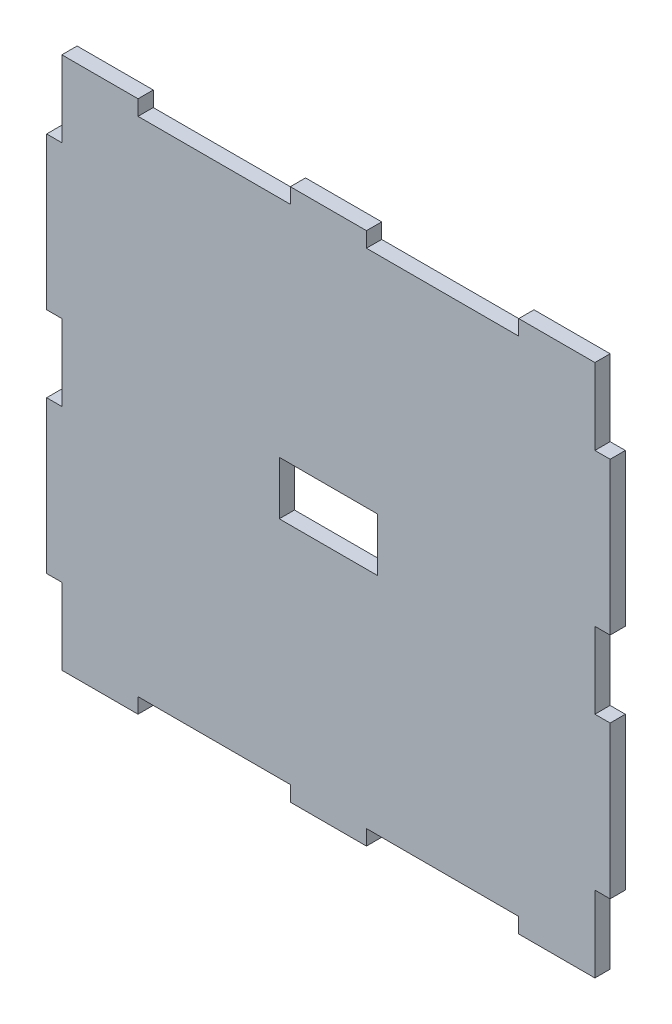
from build123d import *

# Parameters (mm, degrees)
SKETCH1_W           = 70
SKETCH1_H           = 70
BOSS_EXTRUDE1_DEPTH = 2
SKETCH2_W           = 2
SKETCH2_H           = 20
BOSS_EXTRUDE2_DEPTH = 2
SKETCH3_W           = 20
SKETCH3_H           = 2
CUT_EXTRUDE1_DEPTH  = 2
SKETCH4_W           = 12.9
SKETCH4_H           = 7
CUT_EXTRUDE2_DEPTH  = 10


with BuildPart() as part:
    # Sketch1 → Boss-Extrude1 (new body)
    with BuildSketch(Plane.XY):
        Rectangle(SKETCH1_W, SKETCH1_H)
    extrude(amount=-BOSS_EXTRUDE1_DEPTH)

    # Sketch2 → Boss-Extrude2 (add)
    with BuildSketch(Plane.XY):
        with Locations((-36, 15)):
            Rectangle(SKETCH2_W, SKETCH2_H)
        with Locations((-36, -15)):
            Rectangle(SKETCH2_W, SKETCH2_H)
        with Locations((36, -15)):
            Rectangle(SKETCH2_W, SKETCH2_H)
        with Locations((36, 15)):
            Rectangle(SKETCH2_W, SKETCH2_H)
    extrude(amount=-BOSS_EXTRUDE2_DEPTH)

    # Sketch3 → Cut-Extrude1 (cut)
    with BuildSketch(Plane.XY):
        with Locations((-15, 34)):
            Rectangle(SKETCH3_W, SKETCH3_H)
        with Locations((15, 34)):
            Rectangle(SKETCH3_W, SKETCH3_H)
        with Locations((-15, -34)):
            Rectangle(SKETCH3_W, SKETCH3_H)
        with Locations((15, -34)):
            Rectangle(SKETCH3_W, SKETCH3_H)
    extrude(amount=-CUT_EXTRUDE1_DEPTH, mode=Mode.SUBTRACT)

    # Sketch4 → Cut-Extrude2 (cut)
    with BuildSketch(Plane.XY):
        Rectangle(SKETCH4_W, SKETCH4_H)
    extrude(amount=-CUT_EXTRUDE2_DEPTH, mode=Mode.SUBTRACT)


solid = part.part
